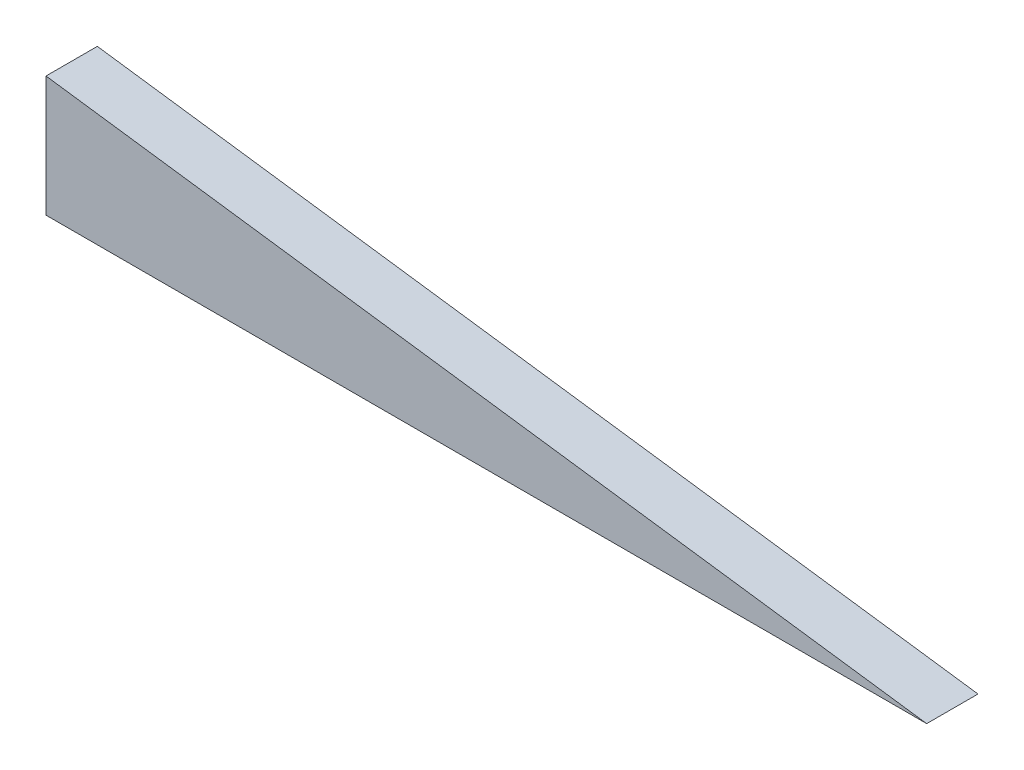
from build123d import *

# Parameters (mm, degrees)
BOSS_EXTRUDE1_DEPTH = 3.175


with BuildPart() as part:
    # Sketch1 → Boss-Extrude1 (new body, symmetric)
    with BuildSketch(Plane.XY):
        Polygon((0, 0), (-108.966, 0), (-108.966, 14.914796948), align=None)
    extrude(amount=BOSS_EXTRUDE1_DEPTH, both=True)


solid = part.part
